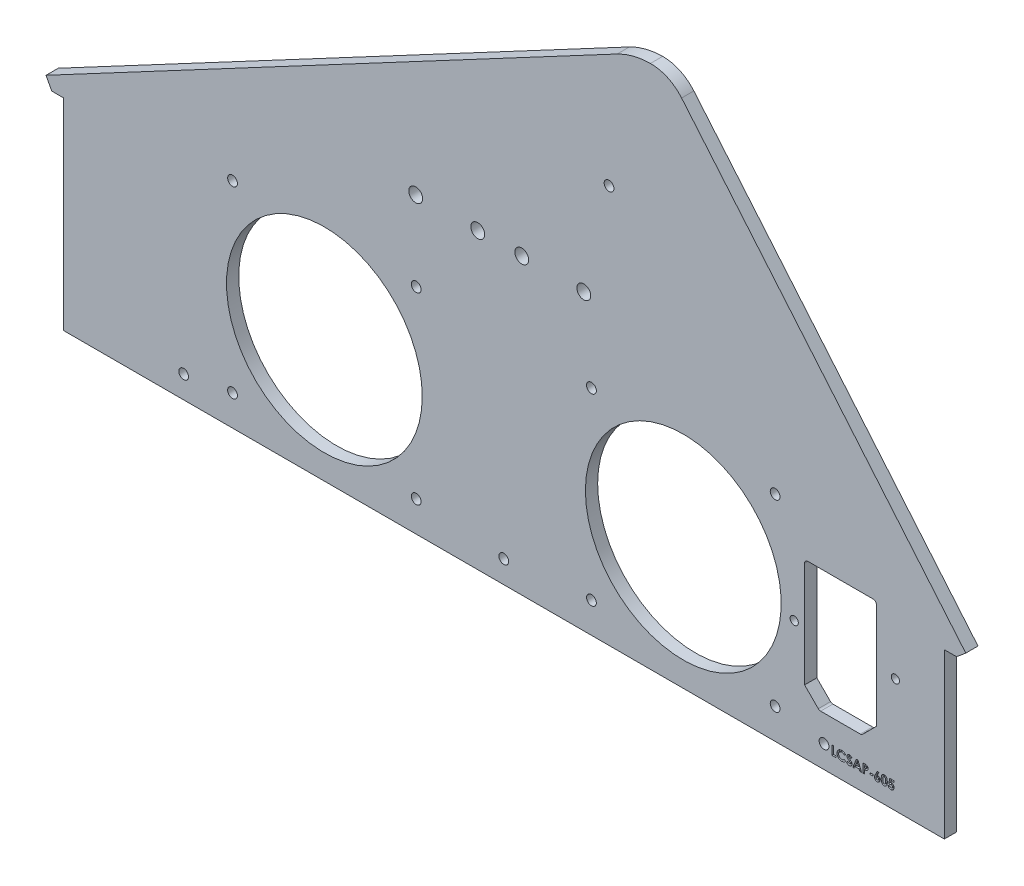
from build123d import *

# Parameters (mm, degrees)
BOSS_EXTRUDE1_DEPTH = 4.7625
SKETCH2_R           = 1.905
CUT_EXTRUDE1_DEPTH  = 407.344943003
SKETCH3_R           = 38.1
SKETCH3_R_2         = 1.905
CUT_EXTRUDE2_DEPTH  = 407.344943003
SKETCH4_R           = 2.69875
CUT_EXTRUDE3_DEPTH  = 407.344943003
SKETCH6_R           = 1.5875
CUT_EXTRUDE4_DEPTH  = 407.344943003
SKETCH7_W           = 1.211538462
SKETCH7_H           = 0.583333334
CUT_EXTRUDE5_DEPTH  = 1.016


with BuildPart() as part:
    # Sketch1 → Boss-Extrude1 (new body)
    with BuildSketch(Plane.XY):
        with BuildLine():
            Line((342.9, 0), (342.9, 63.846084025))
            Line((342.9, 63.846084025), (347.6625, 63.846084025))
            Line((347.6625, 63.846084025), (351.246350093, 66.853291317))
            Line((351.246350093, 66.853291317), (240.642270942, 198.6661))
            ThreePointArc((240.642270942, 198.6661), (235.199196057, 202.821062746), (228.502863126, 204.252811641))
            ThreePointArc((228.502863126, 204.252811641), (221.829642318, 203.38166914), (215.553659607, 200.9521))
            Line((215.553659607, 200.9521), (-6.746192899, 82.628723888))
            Line((-6.746192899, 82.628723888), (-4.5085, 78.424661955))
            Line((-4.5085, 78.424661955), (0, 78.424661955))
            Line((0, 78.424661955), (0, 0))
            Line((0, 0), (342.9, 0))
        make_face()
    extrude(amount=BOSS_EXTRUDE1_DEPTH)

    # Sketch2 → Cut-Extrude1 (cut, through all)
    with BuildSketch(Plane.XY):
        with Locations((46.8249, 8.73125)):
            Circle(SKETCH2_R)
        with Locations((296.0751, 8.73125)):
            Circle(SKETCH2_R)
        with Locations((171.4246, 8.73125)):
            Circle(SKETCH2_R)
        with Locations((212.41385, 154.94)):
            Circle(SKETCH2_R)
    extrude(amount=CUT_EXTRUDE1_DEPTH, mode=Mode.SUBTRACT)

    # Sketch3 → Cut-Extrude2 (cut, through all)
    with BuildSketch(Plane.XY):
        with Locations((101.6, 47.625)):
            Circle(SKETCH3_R)
        with Locations((137.35, 83.375)):
            Circle(SKETCH3_R_2)
        with Locations((65.85, 83.375)):
            Circle(SKETCH3_R_2)
        with Locations((65.85, 11.875)):
            Circle(SKETCH3_R_2)
        with Locations((137.35, 11.875)):
            Circle(SKETCH3_R_2)
        with Locations((205.55, 11.875)):
            Circle(SKETCH3_R_2)
        with Locations((277.05, 11.875)):
            Circle(SKETCH3_R_2)
        with Locations((277.05, 83.375)):
            Circle(SKETCH3_R_2)
        with Locations((205.55, 83.375)):
            Circle(SKETCH3_R_2)
        with Locations((241.3, 47.625)):
            Circle(SKETCH3_R)
    extrude(amount=CUT_EXTRUDE2_DEPTH, mode=Mode.SUBTRACT)

    # Sketch4 → Cut-Extrude3 (cut, through all)
    with BuildSketch(Plane.XY):
        with Locations((137.16, 114.3)):
            Circle(SKETCH4_R)
        with Locations((161.29, 114.3)):
            Circle(SKETCH4_R)
        with Locations((178.435, 114.3)):
            Circle(SKETCH4_R)
        with Locations((202.565, 114.3)):
            Circle(SKETCH4_R)
    extrude(amount=CUT_EXTRUDE3_DEPTH, mode=Mode.SUBTRACT)

    # Sketch6 → Cut-Extrude4 (cut, through all)
    with BuildSketch(Plane.XY):
        with Locations((284.48, 44.45)):
            Circle(SKETCH6_R)
        with Locations((323.85, 44.45)):
            Circle(SKETCH6_R)
        with BuildLine():
            Line((316.45, 24.765), (316.45, 65.786))
            ThreePointArc((316.45, 65.786), (316.078025612, 66.684025612), (315.18, 67.056))
            Line((315.18, 67.056), (289.78, 67.056))
            ThreePointArc((289.78, 67.056), (288.881974388, 66.684025612), (288.51, 65.786))
            Line((288.51, 65.786), (288.51, 24.765))
            Line((288.51, 24.765), (293.853025612, 19.421974388))
            ThreePointArc((293.853025612, 19.421974388), (294.265043265, 19.146672994), (294.751051224, 19.05))
            Line((294.751051224, 19.05), (310.208948776, 19.05))
            ThreePointArc((310.208948776, 19.05), (310.694956735, 19.146672994), (311.106974388, 19.421974388))
            Line((311.106974388, 19.421974388), (316.45, 24.765))
        make_face()
    extrude(amount=CUT_EXTRUDE4_DEPTH, mode=Mode.SUBTRACT)

    # Sketch7 → Cut-Extrude5 (cut)
    # profile 1 of 9: a face of its own
    with BuildSketch(Plane.XY.offset(4.7625)):
        with BuildLine():
            Line((321.671734776, 9.85), (323.265384615, 9.85))
            Line((323.265384615, 9.85), (323.265384615, 9.266666667))
            Line((323.265384615, 9.266666667), (322.16953125, 9.266666667))
            Line((322.16953125, 9.266666667), (322.0328125, 8.604807692))
            add(Edge.make_bspline(
                [(322.0328125, 8.604807692), (322.051442387, 8.609996351), (322.088184351, 8.620229452), (322.143536166, 8.630491957), (322.197179789, 8.637143787), (322.232380406, 8.638031053), (322.249459135, 8.638461538)],
                knots=[0, 0, 0, 0, 1.05461699, 2.079921384, 3.068411212, 4, 4, 4, 4], degree=3))
            add(Edge.make_bspline(
                [(322.249459135, 8.638461538), (322.286675472, 8.637608748), (322.360037073, 8.635927709), (322.467355785, 8.61996917), (322.570119791, 8.594834954), (322.668014623, 8.558988378), (322.76094465, 8.512333132), (322.849022522, 8.455893363), (322.932356339, 8.389569942), (323.009465742, 8.313321345), (323.080317083, 8.229598659), (323.141918283, 8.139043716), (323.194529551, 8.04294774), (323.236374736, 7.940713401), (323.269402522, 7.8329828), (323.293269139, 7.7196869), (323.307382661, 7.600691427), (323.309285783, 7.519509324), (323.31025641, 7.478104968)],
                knots=[0, 0, 0, 0, 1.01440847, 1.999622559, 2.951875003, 3.895578053, 4.836219714, 5.782137149, 6.743708247, 7.735272588, 8.734977101, 9.730283169, 10.717124674, 11.717316708, 12.737475749, 13.78628267, 14.87096371, 16, 16, 16, 16], degree=3))
            add(Edge.make_bspline(
                [(323.31025641, 7.478104968), (323.309070288, 7.436230577), (323.306729723, 7.353600162), (323.291459682, 7.232104224), (323.264507784, 7.115738544), (323.227486655, 7.004191613), (323.178713688, 6.898283274), (323.120057519, 6.796916397), (323.050526432, 6.700843395), (322.970802765, 6.611049133), (322.884132681, 6.528975454), (322.7918495, 6.456775081), (322.69460154, 6.396019052), (322.592386455, 6.346917909), (322.485790684, 6.308069959), (322.374781875, 6.279790505), (322.25882054, 6.26357381), (322.18009786, 6.261374362), (322.140084135, 6.26025641)],
                knots=[0, 0, 0, 0, 1.06808661, 2.107647099, 3.116961351, 4.110378221, 5.100014249, 6.085620622, 7.093190682, 8.119403071, 9.144090782, 10.133780668, 11.103064255, 12.062861538, 13.020824475, 13.992378307, 14.979551724, 16, 16, 16, 16], degree=3))
            add(Edge.make_bspline(
                [(322.140084135, 6.26025641), (322.104301051, 6.261170964), (322.033729322, 6.262974655), (321.929780263, 6.274061093), (321.829561827, 6.293662018), (321.733606064, 6.322029632), (321.64090336, 6.356943689), (321.552525383, 6.400610316), (321.467986482, 6.45219804), (321.387526715, 6.510765386), (321.31245344, 6.576739229), (321.243934509, 6.648958967), (321.1815551, 6.726514305), (321.126650035, 6.810362042), (321.079391424, 6.900378295), (321.037481525, 6.995502204), (321.003177852, 7.096727166), (320.985769726, 7.166901933), (320.976923077, 7.202564103)],
                knots=[0, 0, 0, 0, 1.054957082, 2.080596141, 3.077793124, 4.061112343, 5.027190972, 5.994718051, 6.962465889, 7.943658696, 8.924948258, 9.904494768, 10.875059, 11.855380583, 12.854004648, 13.869083016, 14.917087635, 16, 16, 16, 16], degree=3))
            Line((320.976923077, 7.202564103), (321.694871795, 7.202564103))
            add(Edge.make_bspline(
                [(321.694871795, 7.202564103), (321.707995915, 7.177851671), (321.733501144, 7.129825881), (321.782017729, 7.066064428), (321.836328965, 7.011691401), (321.895944937, 6.966175562), (321.961251917, 6.93207587), (322.029588771, 6.906216242), (322.101813985, 6.89127292), (322.151002544, 6.889404857), (322.175841346, 6.888461538)],
                knots=[0, 0, 0, 0, 1.104910296, 2.147267069, 3.153527244, 4.136738762, 5.099945312, 6.05603338, 7.018353, 8, 8, 8, 8], degree=3))
            add(Edge.make_bspline(
                [(322.175841346, 6.888461538), (322.193153658, 6.889112908), (322.227215923, 6.890394488), (322.277401284, 6.897174369), (322.325305416, 6.910015309), (322.371284475, 6.927797026), (322.415461972, 6.949972835), (322.457204607, 6.97796835), (322.497238628, 7.010192225), (322.534954553, 7.047169231), (322.56911431, 7.088389992), (322.59906868, 7.132684509), (322.625852018, 7.179068549), (322.645690846, 7.229379501), (322.661937169, 7.282115061), (322.673901618, 7.33767303), (322.681051725, 7.396118294), (322.681713634, 7.436017238), (322.682051282, 7.456370192)],
                knots=[0, 0, 0, 0, 0.978869489, 1.925942215, 2.855067702, 3.774946051, 4.70828698, 5.642468714, 6.60995405, 7.609372294, 8.622401667, 9.629904756, 10.629323, 11.642352373, 12.678539694, 13.745912462, 14.850161547, 16, 16, 16, 16], degree=3))
            add(Edge.make_bspline(
                [(322.682051282, 7.456370192), (322.681659403, 7.476250708), (322.6808966, 7.514948615), (322.674586541, 7.571771003), (322.663297967, 7.625685166), (322.647917189, 7.677104046), (322.628227956, 7.725715402), (322.604166398, 7.771808594), (322.57562972, 7.815150636), (322.542464716, 7.854859127), (322.507097896, 7.891280884), (322.469102568, 7.923135063), (322.428821049, 7.94957182), (322.387505036, 7.972651878), (322.343505345, 7.989449041), (322.297811351, 8.001016627), (322.250471107, 8.009504457), (322.218181354, 8.010003148), (322.201782853, 8.01025641)],
                knots=[0, 0, 0, 0, 1.166249705, 2.270133367, 3.348514167, 4.393962215, 5.415026464, 6.420877785, 7.440098956, 8.453121383, 9.451844239, 10.415694839, 11.355045125, 12.27538808, 13.187007209, 14.108269027, 15.039275622, 16, 16, 16, 16], degree=3))
            add(Edge.make_bspline(
                [(322.201782853, 8.01025641), (322.183970269, 8.009580522), (322.14827003, 8.008225896), (322.09522841, 7.997203668), (322.042826324, 7.979365569), (321.990772364, 7.954755084), (321.939583254, 7.922547724), (321.887908089, 7.884772184), (321.837476548, 7.838683712), (321.805410771, 7.804356913), (321.788822115, 7.786598558)],
                knots=[0, 0, 0, 0, 0.88288272, 1.769486374, 2.674910571, 3.623812639, 4.617874466, 5.670434592, 6.794841017, 8, 8, 8, 8], degree=3))
            Line((321.788822115, 7.786598558), (321.260176282, 7.907892628))
            Line((321.260176282, 7.907892628), (321.671734776, 9.85))
        make_face()
    # profile 2 of 9: a face of its own
    with BuildSketch(Plane.XY.offset(4.7625)):
        with BuildLine():
            add(Edge.make_bspline(
                [(319.508072917, 9.93974359), (319.538480652, 9.939292178), (319.598270385, 9.938404583), (319.686329406, 9.928791201), (319.771154591, 9.914268063), (319.853077785, 9.894013349), (319.931509297, 9.867206957), (320.007019968, 9.835120165), (320.078711003, 9.796069956), (320.147496691, 9.751960738), (320.213350535, 9.702022851), (320.274689786, 9.64509108), (320.332634627, 9.58247543), (320.385930767, 9.513229263), (320.435758465, 9.437982447), (320.481953994, 9.35672305), (320.524163718, 9.269053361), (320.562860706, 9.174815174), (320.597463675, 9.072595899), (320.626609713, 8.961223037), (320.651607317, 8.840671153), (320.672707059, 8.710640176), (320.688655053, 8.570957264), (320.699404323, 8.421715214), (320.70678098, 8.263201744), (320.707383012, 8.154462806), (320.707692308, 8.098597756)],
                knots=[0, 0, 0, 0, 0.879237366, 1.728815576, 2.559023295, 3.367336655, 4.166867292, 4.954216142, 5.737608147, 6.525189134, 7.316157332, 8.124696809, 8.942788509, 9.781158001, 10.649253743, 11.551476218, 12.482711956, 13.461909668, 14.496590415, 15.601789533, 16.789733467, 18.056700938, 19.410929216, 20.8549011, 22.384193279, 24, 24, 24, 24], degree=3))
            add(Edge.make_bspline(
                [(320.707692308, 8.098597756), (320.707358042, 8.042033772), (320.706708571, 7.932130965), (320.699710973, 7.77216765), (320.687660778, 7.621842014), (320.672129618, 7.481169608), (320.650856176, 7.350224719), (320.625942019, 7.228668289), (320.59633592, 7.116544378), (320.560593141, 7.014105625), (320.522130387, 6.919701935), (320.479805201, 6.832203181), (320.434355307, 6.751372369), (320.386823186, 6.675990055), (320.334602955, 6.608278471), (320.280236318, 6.545935071), (320.221356056, 6.491334593), (320.160441254, 6.441663175), (320.095260358, 6.398737102), (320.02648556, 6.361194666), (319.952890726, 6.330743291), (319.875817364, 6.304258312), (319.793951743, 6.285244955), (319.708594697, 6.27015848), (319.618782561, 6.261820769), (319.557634842, 6.260786421), (319.526302083, 6.26025641)],
                knots=[0, 0, 0, 0, 1.643780988, 3.193836972, 4.651895693, 6.025988579, 7.305620092, 8.505800249, 9.631074763, 10.672816429, 11.65661981, 12.592235626, 13.49536222, 14.350718032, 15.179365177, 15.97804903, 16.751647189, 17.51006938, 18.259804725, 19.016521909, 19.783502495, 20.571750527, 21.382245291, 22.22305063, 23.089471752, 24, 24, 24, 24], degree=3))
            add(Edge.make_bspline(
                [(319.526302083, 6.26025641), (319.49497017, 6.260796645), (319.433591414, 6.261854957), (319.343536417, 6.270096486), (319.257727022, 6.28530607), (319.175213712, 6.304404282), (319.096570768, 6.33068469), (319.0214211, 6.362047148), (318.950342543, 6.399355338), (318.883138292, 6.442381425), (318.820037802, 6.491720504), (318.76006049, 6.546844838), (318.703339031, 6.607614701), (318.650736299, 6.674710765), (318.601390812, 6.747237439), (318.555817167, 6.826022941), (318.514042751, 6.910952561), (318.474760854, 7.002144684), (318.440629858, 7.10156257), (318.410254856, 7.210094009), (318.385372454, 7.3286437), (318.36536036, 7.457173557), (318.349382717, 7.595411285), (318.337497186, 7.743423606), (318.33046072, 7.901279462), (318.329818059, 8.009781655), (318.329487179, 8.065645032)],
                knots=[0, 0, 0, 0, 0.917216111, 1.796812873, 2.643793957, 3.46689424, 4.273913431, 5.068098542, 5.848489301, 6.620921603, 7.401012384, 8.190319798, 9.003608147, 9.831726257, 10.68377682, 11.569763213, 12.493818149, 13.453288342, 14.474581811, 15.568529029, 16.750744269, 18.018426408, 19.375425659, 20.823733699, 22.36466933, 24, 24, 24, 24], degree=3))
            add(Edge.make_bspline(
                [(318.329487179, 8.065645032), (318.330086537, 8.143262797), (318.331243006, 8.293027275), (318.345898626, 8.509393402), (318.36740936, 8.709386406), (318.399003532, 8.892671749), (318.438069289, 9.059928265), (318.488095025, 9.210054156), (318.545045686, 9.345126752), (318.593574966, 9.425144571), (318.616947115, 9.463681891)],
                knots=[0, 0, 0, 0, 1.288568992, 2.486310467, 3.599230591, 4.627010532, 5.572937695, 6.447898582, 7.252493626, 8, 8, 8, 8], degree=3))
            add(Edge.make_bspline(
                [(318.616947115, 9.463681891), (318.644123137, 9.501540942), (318.697257615, 9.575562848), (318.790164735, 9.672739774), (318.889981339, 9.755850239), (318.998757603, 9.82301338), (319.114773185, 9.875978238), (319.239024139, 9.913386721), (319.371051626, 9.935182647), (319.461717103, 9.938200572), (319.508072917, 9.93974359)],
                knots=[0, 0, 0, 0, 1.058512271, 2.069600068, 3.047294572, 4.004278952, 4.967380941, 5.939006123, 6.946246673, 8, 8, 8, 8], degree=3))
        make_face()
        with BuildLine():
            add(Edge.make_bspline(
                [(319.523497596, 9.311538462), (319.496008751, 9.310235545), (319.442116023, 9.307681137), (319.363915106, 9.285997815), (319.290176524, 9.252506756), (319.234085555, 9.212205503), (319.192102022, 9.173571918), (319.162767826, 9.138609781), (319.134479618, 9.099594555), (319.109494048, 9.054765685), (319.085901148, 9.005733924), (319.062843773, 8.952276698), (319.04394278, 8.893080981), (319.025373055, 8.829154885), (319.009104244, 8.758731022), (318.995474546, 8.681233756), (318.98329761, 8.596159114), (318.974804052, 8.503451372), (318.966885506, 8.403207526), (318.961209118, 8.295204271), (318.958835962, 8.179470744), (318.958081608, 8.099766781), (318.957692308, 8.058633814)],
                knots=[0, 0, 0, 0, 1.076674018, 2.110852608, 3.161083442, 4.239746716, 4.804137807, 5.395870207, 6.026861976, 6.692161227, 7.405688833, 8.16177676, 8.973626916, 9.841385931, 10.773283133, 11.807421078, 12.927755683, 14.143907515, 15.458935494, 16.872852025, 18.386167141, 20, 20, 20, 20], degree=3))
            add(Edge.make_bspline(
                [(318.957692308, 8.058633814), (318.95833305, 8.005344067), (318.95956172, 7.903157026), (318.965996919, 7.756208503), (318.978895741, 7.622473515), (318.994939272, 7.501045689), (319.017473067, 7.392712518), (319.043399656, 7.29644907), (319.075416688, 7.21348247), (319.112418538, 7.142612834), (319.153399754, 7.082324181), (319.197886667, 7.031078555), (319.244364656, 6.986702261), (319.294284452, 6.950655944), (319.34752696, 6.923031708), (319.403647703, 6.903161936), (319.462682345, 6.890998822), (319.503108659, 6.889312189), (319.523497596, 6.888461538)],
                knots=[0, 0, 0, 0, 1.771748488, 3.397459088, 4.888034009, 6.237357457, 7.467047327, 8.564189669, 9.548206622, 10.417051504, 11.216568818, 11.965764335, 12.669334354, 13.348544111, 14.005342236, 14.656555988, 15.322436492, 16, 16, 16, 16], degree=3))
            add(Edge.make_bspline(
                [(319.523497596, 6.888461538), (319.54318685, 6.889043617), (319.581735959, 6.890183253), (319.637949195, 6.901881469), (319.691108425, 6.920900227), (319.741053145, 6.947803595), (319.787962, 6.982015344), (319.831605729, 7.023685815), (319.871655179, 7.073230366), (319.894988171, 7.109999749), (319.907011218, 7.128946314)],
                knots=[0, 0, 0, 0, 0.992283464, 1.942767638, 2.88273346, 3.832339453, 4.79467288, 5.803907806, 6.868395428, 8, 8, 8, 8], degree=3))
            add(Edge.make_bspline(
                [(319.907011218, 7.128946314), (319.921166331, 7.154836189), (319.950848455, 7.209125158), (319.985196661, 7.300735767), (320.014109066, 7.404057394), (320.03899355, 7.519411585), (320.056013019, 7.64725331), (320.070670165, 7.786771915), (320.077739671, 7.938669958), (320.078889565, 8.04390547), (320.079487179, 8.098597756)],
                knots=[0, 0, 0, 0, 0.710965849, 1.490837728, 2.352621235, 3.297892224, 4.334225155, 5.461620853, 6.680770821, 8, 8, 8, 8], degree=3))
            add(Edge.make_bspline(
                [(320.079487179, 8.098597756), (320.079256334, 8.153764798), (320.078811995, 8.259951935), (320.070659668, 8.412396063), (320.05930693, 8.551628473), (320.042701151, 8.677338316), (320.021334799, 8.789830761), (319.995000689, 8.889098454), (319.963954732, 8.975337033), (319.927137927, 9.048460505), (319.886361029, 9.110605426), (319.843075106, 9.163920947), (319.797097128, 9.209440394), (319.748503986, 9.247335064), (319.696170975, 9.276289435), (319.641097722, 9.296733616), (319.583171324, 9.309101659), (319.54365732, 9.310715231), (319.523497596, 9.311538462)],
                knots=[0, 0, 0, 0, 1.793836731, 3.452829483, 4.963243077, 6.335886805, 7.574563692, 8.684454726, 9.672768357, 10.54971625, 11.340229787, 12.085688095, 12.778991901, 13.440269426, 14.083255152, 14.715733572, 15.344777694, 16, 16, 16, 16], degree=3))
        make_face(mode=Mode.SUBTRACT)
    # profile 3 of 9: a face of its own
    with BuildSketch(Plane.XY.offset(4.7625)):
        with BuildLine():
            Line((316.879567308, 9.93974359), (317.435556891, 9.657892628))
            Line((317.435556891, 9.657892628), (316.825580929, 8.458974359))
            add(Edge.make_bspline(
                [(316.825580929, 8.458974359), (316.861617737, 8.458041348), (316.932598139, 8.456203629), (317.037031398, 8.441350882), (317.136871538, 8.415674043), (317.233125242, 8.381639463), (317.3246159, 8.335930683), (317.41281702, 8.281557705), (317.495446794, 8.21524401), (317.574399853, 8.141771954), (317.646191464, 8.060375475), (317.70855517, 7.972912373), (317.762904039, 7.881510636), (317.805152663, 7.784125384), (317.839231809, 7.68237089), (317.863821413, 7.575840396), (317.87785047, 7.464225415), (317.87978461, 7.388400302), (317.880769231, 7.349799679)],
                knots=[0, 0, 0, 0, 1.013260694, 1.995783107, 2.958651975, 3.908806537, 4.861209129, 5.829647963, 6.817170299, 7.835534541, 8.860094905, 9.863329007, 10.853101798, 11.844815043, 12.84250023, 13.867713965, 14.914507806, 16, 16, 16, 16], degree=3))
            add(Edge.make_bspline(
                [(317.880769231, 7.349799679), (317.87984656, 7.312591021), (317.878022834, 7.239045459), (317.862947329, 7.131025732), (317.838584522, 7.027387122), (317.803765177, 6.928336607), (317.759506974, 6.833390025), (317.70538219, 6.742603092), (317.640941964, 6.656654229), (317.567851255, 6.576000127), (317.4879505, 6.502483317), (317.403730752, 6.437137297), (317.314478345, 6.383159006), (317.221880252, 6.337573073), (317.124231686, 6.303556092), (317.022993963, 6.277879165), (316.917399368, 6.263062463), (316.845724462, 6.261199246), (316.809455128, 6.26025641)],
                knots=[0, 0, 0, 0, 1.049934834, 2.075270938, 3.072134561, 4.05064612, 5.033440221, 6.024524368, 7.028587226, 8.060776465, 9.092543989, 10.090062252, 11.064205434, 12.031961459, 12.998029633, 13.977230324, 14.976426867, 16, 16, 16, 16], degree=3))
            add(Edge.make_bspline(
                [(316.809455128, 6.26025641), (316.771528427, 6.261030145), (316.696950701, 6.26255159), (316.587824824, 6.279587767), (316.483163715, 6.305233356), (316.383555588, 6.3418509), (316.288381009, 6.388476396), (316.198760487, 6.446170758), (316.113939094, 6.514297771), (316.034821149, 6.591324685), (315.963541777, 6.675697131), (315.899966534, 6.763297697), (315.846181797, 6.854263848), (315.802644306, 6.948498322), (315.768675345, 7.045700839), (315.745039877, 7.14605588), (315.729639188, 7.249297254), (315.727833809, 7.319362693), (315.726923077, 7.354707532)],
                knots=[0, 0, 0, 0, 1.063775006, 2.091769615, 3.092589432, 4.084662827, 5.064601646, 6.061867366, 7.070035304, 8.113879863, 9.156342271, 10.166834137, 11.149076039, 12.117706134, 13.076241869, 14.034148791, 15.008317125, 16, 16, 16, 16], degree=3))
            add(Edge.make_bspline(
                [(315.726923077, 7.354707532), (315.72740429, 7.382077976), (315.728369394, 7.436971218), (315.738068118, 7.519170865), (315.752813586, 7.601586278), (315.769905513, 7.671131014), (315.787505052, 7.729938366), (315.805219124, 7.779705439), (315.827171813, 7.834936007), (315.852266989, 7.895771109), (315.881293802, 7.962137558), (315.914100623, 8.033854458), (315.950769126, 8.111464902), (315.976918819, 8.16477126), (315.990544872, 8.192548077)],
                knots=[0, 0, 0, 0, 1.110454016, 2.227089276, 3.35462975, 4.507227546, 5.131400587, 5.845402449, 6.650387134, 7.543487832, 8.516250726, 9.590168902, 10.744287919, 12, 12, 12, 12], degree=3))
            Line((315.990544872, 8.192548077), (316.879567308, 9.93974359))
        make_face()
        with BuildLine():
            add(Edge.make_bspline(
                [(316.795432692, 7.875641026), (316.765289498, 7.874258421), (316.706303224, 7.871552845), (316.622433564, 7.843218739), (316.545963463, 7.798769578), (316.479678234, 7.736865525), (316.424236738, 7.662887751), (316.383496382, 7.578506218), (316.358988794, 7.484846975), (316.356442612, 7.419361994), (316.355128205, 7.385556891)],
                knots=[0, 0, 0, 0, 0.981744412, 1.921144944, 2.858899012, 3.85339082, 4.86292663, 5.863643845, 6.897155691, 8, 8, 8, 8], degree=3))
            add(Edge.make_bspline(
                [(316.355128205, 7.385556891), (316.356684504, 7.351740531), (316.35971161, 7.285965451), (316.385140716, 7.191414405), (316.426776052, 7.105116665), (316.485166957, 7.030158525), (316.553717039, 6.967937465), (316.62973095, 6.921922016), (316.71194075, 6.893653216), (316.768807276, 6.890204047), (316.797536058, 6.888461538)],
                knots=[0, 0, 0, 0, 1.098279937, 2.136227893, 3.159405121, 4.194678092, 5.206500211, 6.154139736, 7.067477469, 8, 8, 8, 8], degree=3))
            add(Edge.make_bspline(
                [(316.797536058, 6.888461538), (316.827876898, 6.890235082), (316.887380557, 6.89371331), (316.973218487, 6.920792611), (317.051631951, 6.96603715), (317.12096462, 7.028059004), (317.180520066, 7.102161771), (317.221726419, 7.188966412), (317.248331124, 7.284199894), (317.251121474, 7.351013724), (317.252564103, 7.385556891)],
                knots=[0, 0, 0, 0, 0.96921794, 1.900804717, 2.848419905, 3.844199796, 4.861108892, 5.867439427, 6.897452859, 8, 8, 8, 8], degree=3))
            add(Edge.make_bspline(
                [(317.252564103, 7.385556891), (317.250920685, 7.419342255), (317.247738015, 7.484771558), (317.223832395, 7.578869573), (317.181150523, 7.662925868), (317.124454619, 7.737170894), (317.055888204, 7.799047343), (316.976357614, 7.843569279), (316.888656648, 7.871502646), (316.826960415, 7.874241453), (316.795432692, 7.875641026)],
                knots=[0, 0, 0, 0, 1.083229974, 2.097801324, 3.086792542, 4.086858909, 5.079819718, 6.026392613, 6.991456328, 8, 8, 8, 8], degree=3))
        make_face(mode=Mode.SUBTRACT)
    # profile 4 of 9: a face of its own
    with BuildSketch(Plane.XY.offset(4.7625)):
        with Locations((314.492948718, 7.628846154)):
            Rectangle(SKETCH7_W, SKETCH7_H)
    # profile 5 of 9: a face of its own
    with BuildSketch(Plane.XY.offset(4.7625)):
        with BuildLine():
            Line((311.194871795, 9.85), (311.89599359, 9.85))
            add(Edge.make_bspline(
                [(311.89599359, 9.85), (311.941803978, 9.849794943), (312.03018182, 9.849399345), (312.157629939, 9.844602193), (312.27520707, 9.836005403), (312.382886197, 9.825381131), (312.480623048, 9.810486316), (312.568540018, 9.793410575), (312.646655351, 9.772607354), (312.715849914, 9.747914219), (312.777949799, 9.718801977), (312.83671632, 9.687795361), (312.890821346, 9.650790059), (312.942995721, 9.611774345), (312.990256547, 9.567021062), (313.035552237, 9.519508606), (313.076964394, 9.467352673), (313.114684908, 9.411184597), (313.148903226, 9.352042122), (313.178798638, 9.28981952), (313.203048122, 9.22441833), (313.223390424, 9.156261623), (313.239729559, 9.085352371), (313.250605407, 9.011254473), (313.25799283, 8.934485311), (313.258644668, 8.882236171), (313.258974359, 8.855809295)],
                knots=[0, 0, 0, 0, 1.698747864, 3.27724071, 4.728299578, 6.070144658, 7.288476769, 8.393259625, 9.389771311, 10.283485332, 11.113357557, 11.931608583, 12.74405601, 13.541433047, 14.344816069, 15.154114104, 15.974336324, 16.810834471, 17.661136416, 18.50621059, 19.367396281, 20.244825668, 21.142564693, 22.063065223, 23.020325768, 24, 24, 24, 24], degree=3))
            add(Edge.make_bspline(
                [(313.258974359, 8.855809295), (313.258497338, 8.826573871), (313.257559933, 8.769122669), (313.248370347, 8.684906257), (313.23267163, 8.604613532), (313.212154229, 8.527567372), (313.183544171, 8.455035358), (313.150858523, 8.385286853), (313.11064481, 8.320277391), (313.064694213, 8.259193782), (313.014510919, 8.201539387), (312.958903578, 8.148978868), (312.898932091, 8.101153923), (312.834943611, 8.057563341), (312.766697906, 8.018295054), (312.694244218, 7.982981357), (312.617087793, 7.952751692), (312.56335838, 7.936941821), (312.536117788, 7.928926282)],
                knots=[0, 0, 0, 0, 1.102006807, 2.165578795, 3.188629044, 4.184801286, 5.166646146, 6.124351954, 7.085497154, 8.042432466, 9.003981491, 9.963833307, 10.922997304, 11.89326795, 12.880200226, 13.889073926, 14.929769137, 16, 16, 16, 16], degree=3))
            add(Edge.make_bspline(
                [(312.536117788, 7.928926282), (312.518175568, 7.924462228), (312.479306939, 7.914791651), (312.414990035, 7.904973587), (312.340871557, 7.895946482), (312.25671183, 7.888188777), (312.162462334, 7.882915346), (312.058214328, 7.87879703), (311.943920568, 7.87580259), (311.864445207, 7.875696334), (311.823076923, 7.875641026)],
                knots=[0, 0, 0, 0, 0.618981996, 1.340914327, 2.176866532, 3.120127938, 4.170906482, 5.338178032, 6.614476169, 8, 8, 8, 8], degree=3))
            Line((311.823076923, 7.875641026), (311.823076923, 6.35))
            Line((311.823076923, 6.35), (311.194871795, 6.35))
            Line((311.194871795, 6.35), (311.194871795, 9.85))
        make_face()
        with BuildLine():
            Line((311.823076923, 8.503846154), (312.045332532, 8.503846154))
            add(Edge.make_bspline(
                [(312.045332532, 8.503846154), (312.085775449, 8.504102593), (312.160191017, 8.504574446), (312.261816404, 8.511397707), (312.343484521, 8.521818204), (312.408003849, 8.536763608), (312.45894797, 8.559445236), (312.502884084, 8.585683609), (312.540569212, 8.618861312), (312.573198985, 8.656772514), (312.599285506, 8.700334385), (312.617375149, 8.748837605), (312.629125826, 8.801263069), (312.63021111, 8.837747722), (312.630769231, 8.856510417)],
                knots=[0, 0, 0, 0, 1.8619151, 3.425951444, 4.686033666, 5.651700536, 6.461346321, 7.243864085, 7.999046032, 8.762387399, 9.539336099, 10.322741239, 11.137448474, 12, 12, 12, 12], degree=3))
            add(Edge.make_bspline(
                [(312.630769231, 8.856510417), (312.630216851, 8.872903138), (312.629145101, 8.904708959), (312.621271733, 8.950612649), (312.608723849, 8.993404356), (312.590542447, 9.03263718), (312.567038201, 9.068244457), (312.538381767, 9.100212159), (312.504940866, 9.129224904), (312.479122535, 9.144581793), (312.466005609, 9.152383814)],
                knots=[0, 0, 0, 0, 1.102301479, 2.1387299, 3.123554645, 4.094223062, 5.036071848, 5.982632524, 6.975082478, 8, 8, 8, 8], degree=3))
            add(Edge.make_bspline(
                [(312.466005609, 9.152383814), (312.454894815, 9.158002861), (312.431370989, 9.169899535), (312.391307631, 9.183730288), (312.345075129, 9.195398051), (312.292361359, 9.205082183), (312.233376613, 9.212598074), (312.168131415, 9.218345851), (312.096529749, 9.220657256), (312.046735075, 9.221405207), (312.020793269, 9.221794872)],
                knots=[0, 0, 0, 0, 0.656809284, 1.390599849, 2.23162475, 3.173112763, 4.218524733, 5.370385145, 6.63003504, 8, 8, 8, 8], degree=3))
            Line((312.020793269, 9.221794872), (311.823076923, 9.221794872))
            Line((311.823076923, 9.221794872), (311.823076923, 8.503846154))
        make_face(mode=Mode.SUBTRACT)
    # profile 6 of 9: a face of its own
    with BuildSketch(Plane.XY.offset(4.7625)):
        Polygon((308.682752404, 9.85), (309.265384615, 9.85), (310.678846154, 6.35), (310.007872596, 6.35), (309.73583734, 7.067948718), (308.210897436, 7.067948718), (307.938862179, 6.35), (307.268589744, 6.35), align=None)
        Polygon((308.973717949, 8.911197917), (308.449278846, 7.696153846), (309.498157051, 7.696153846), align=None, mode=Mode.SUBTRACT)
    # profile 7 of 9: a face of its own
    with BuildSketch(Plane.XY.offset(4.7625)):
        with BuildLine():
            Line((306.887179487, 9.382351763), (306.417427885, 8.952564103))
            add(Edge.make_bspline(
                [(306.417427885, 8.952564103), (306.39730574, 8.980948479), (306.358674029, 9.035442524), (306.296056055, 9.108411334), (306.233720833, 9.17065916), (306.171090865, 9.221925958), (306.107611023, 9.261900244), (306.0433915, 9.290202481), (305.978796372, 9.308194481), (305.935398418, 9.310434918), (305.914022436, 9.311538462)],
                knots=[0, 0, 0, 0, 1.299362458, 2.494594718, 3.587462134, 4.587049575, 5.512617175, 6.380583204, 7.202344345, 8, 8, 8, 8], degree=3))
            add(Edge.make_bspline(
                [(305.914022436, 9.311538462), (305.894083533, 9.310839206), (305.855586751, 9.309489126), (305.800706732, 9.296069437), (305.751983469, 9.272909025), (305.709464515, 9.242624837), (305.67578323, 9.206139412), (305.648891336, 9.167875583), (305.63374894, 9.125640968), (305.631755902, 9.096632532), (305.630769231, 9.082271635)],
                knots=[0, 0, 0, 0, 1.185010067, 2.2879431, 3.333075148, 4.379039566, 5.372662701, 6.27520591, 7.14612461, 8, 8, 8, 8], degree=3))
            add(Edge.make_bspline(
                [(305.630769231, 9.082271635), (305.631387528, 9.067703647), (305.632632692, 9.038365745), (305.644659286, 8.995367395), (305.662786797, 8.953353002), (305.680108374, 8.927776842), (305.68896234, 8.914703526)],
                knots=[0, 0, 0, 0, 0.967525499, 1.948461899, 2.951351359, 4, 4, 4, 4], degree=3))
            add(Edge.make_bspline(
                [(305.68896234, 8.914703526), (305.697011552, 8.904541774), (305.715539777, 8.881150764), (305.750869306, 8.84410305), (305.795235775, 8.798716357), (305.850346498, 8.746551401), (305.913913679, 8.685732126), (305.988883738, 8.618649361), (306.073098709, 8.543225631), (306.13295676, 8.490703276), (306.164322917, 8.46318109)],
                knots=[0, 0, 0, 0, 0.473873513, 1.090794244, 1.870441696, 2.795289791, 3.865433203, 5.087734844, 6.473946851, 8, 8, 8, 8], degree=3))
            add(Edge.make_bspline(
                [(306.164322917, 8.46318109), (306.193764567, 8.437700826), (306.249638703, 8.38934458), (306.329136503, 8.320710653), (306.399001829, 8.258962381), (306.460252459, 8.205026476), (306.511959893, 8.158337026), (306.554341511, 8.118670855), (306.587914931, 8.086800191), (306.606999454, 8.067550291), (306.615144231, 8.059334936)],
                knots=[0, 0, 0, 0, 1.543621617, 2.929473131, 4.163658386, 5.240097082, 6.164993805, 6.925417477, 7.541396219, 8, 8, 8, 8], degree=3))
            add(Edge.make_bspline(
                [(306.615144231, 8.059334936), (306.646043815, 8.025894968), (306.705443668, 7.961611605), (306.782642537, 7.861992611), (306.846179703, 7.764744159), (306.89533326, 7.668036363), (306.932456003, 7.570473922), (306.958628028, 7.469664122), (306.974302628, 7.364553564), (306.976042875, 7.292828439), (306.976923077, 7.256550481)],
                knots=[0, 0, 0, 0, 1.206664779, 2.319633467, 3.337109185, 4.282041471, 5.190008762, 6.099243693, 7.03861361, 8, 8, 8, 8], degree=3))
            add(Edge.make_bspline(
                [(306.976923077, 7.256550481), (306.976296572, 7.221202059), (306.975067345, 7.151847141), (306.960011678, 7.050356549), (306.938543179, 6.953225647), (306.905349114, 6.861511358), (306.864892385, 6.773708218), (306.814174031, 6.691183923), (306.754612279, 6.613103292), (306.686345367, 6.540862112), (306.610834055, 6.475308248), (306.529840996, 6.41695065), (306.4425742, 6.36876902), (306.34977926, 6.329094884), (306.251505848, 6.298537334), (306.147871036, 6.275952457), (306.038716308, 6.262397369), (305.964074733, 6.260980346), (305.925941506, 6.26025641)],
                knots=[0, 0, 0, 0, 1.043214005, 2.046824704, 3.02475056, 3.976699089, 4.921714032, 5.875962561, 6.831408892, 7.817874052, 8.806269674, 9.781291748, 10.760897367, 11.74438705, 12.757449933, 13.795994037, 14.874007457, 16, 16, 16, 16], degree=3))
            add(Edge.make_bspline(
                [(305.925941506, 6.26025641), (305.896007249, 6.260787464), (305.836720251, 6.261839255), (305.749340179, 6.270426251), (305.664964843, 6.284284751), (305.583689282, 6.30414812), (305.505147336, 6.329317702), (305.42933578, 6.360061383), (305.356777966, 6.396855678), (305.286924887, 6.43894395), (305.220116116, 6.487813977), (305.155506881, 6.542466629), (305.093738943, 6.603742487), (305.034515643, 6.671496636), (304.978215908, 6.74592094), (304.922996846, 6.825978902), (304.871312559, 6.91315629), (304.839384875, 6.974311933), (304.823076923, 7.005548878)],
                knots=[0, 0, 0, 0, 1.016823716, 2.013894106, 2.979844003, 3.91962641, 4.853723003, 5.779685073, 6.695824784, 7.614987388, 8.547259901, 9.504950863, 10.487499108, 11.500346958, 12.559593716, 13.656357062, 14.802919212, 16, 16, 16, 16], degree=3))
            Line((304.823076923, 7.005548878), (305.375560897, 7.337179487))
            add(Edge.make_bspline(
                [(305.375560897, 7.337179487), (305.395959708, 7.301721473), (305.435065971, 7.23374543), (305.501335191, 7.142411001), (305.569224623, 7.064198182), (305.64030381, 7.000489388), (305.713708457, 6.950432751), (305.789793124, 6.914658806), (305.868611268, 6.892514774), (305.922298607, 6.889810476), (305.949078526, 6.888461538)],
                knots=[0, 0, 0, 0, 1.283663364, 2.460892379, 3.537111102, 4.529833553, 5.449777664, 6.316464042, 7.160231139, 8, 8, 8, 8], degree=3))
            add(Edge.make_bspline(
                [(305.949078526, 6.888461538), (305.976317537, 6.889563154), (306.029165185, 6.891700449), (306.10459844, 6.911441996), (306.173758505, 6.942437673), (306.233539954, 6.98666423), (306.284159116, 7.037708399), (306.321518963, 7.094497371), (306.344988671, 7.155941668), (306.347469988, 7.198624918), (306.348717949, 7.220092147)],
                knots=[0, 0, 0, 0, 1.13588714, 2.203786484, 3.234766741, 4.283437687, 5.291419208, 6.222934724, 7.106237994, 8, 8, 8, 8], degree=3))
            add(Edge.make_bspline(
                [(306.348717949, 7.220092147), (306.347565508, 7.240063911), (306.345224436, 7.280634636), (306.32798082, 7.34095678), (306.301023789, 7.401251492), (306.269131721, 7.450706845), (306.236677547, 7.492114472), (306.205644037, 7.527992307), (306.167853432, 7.567631034), (306.123401551, 7.611080516), (306.07287572, 7.658723248), (306.016233377, 7.710554566), (305.952825908, 7.766117898), (305.908009383, 7.80396709), (305.884575321, 7.823758013)],
                knots=[0, 0, 0, 0, 0.916159276, 1.861089862, 2.860218735, 3.940849679, 4.552606315, 5.27541173, 6.11797699, 7.06649574, 8.129236253, 9.306560635, 10.591630461, 12, 12, 12, 12], degree=3))
            add(Edge.make_bspline(
                [(305.884575321, 7.823758013), (305.840026234, 7.861450812), (305.754523053, 7.933794702), (305.633696211, 8.04064435), (305.524820407, 8.140505137), (305.428836011, 8.23461156), (305.344520031, 8.321225691), (305.272443494, 8.401051045), (305.213398192, 8.474703364), (305.151265743, 8.561939606), (305.092227494, 8.668242962), (305.041201694, 8.796138223), (305.008098308, 8.924017255), (305.004389534, 9.009868194), (305.002564103, 9.052123397)],
                knots=[0, 0, 0, 0, 1.345494975, 2.582412109, 3.71882943, 4.751509156, 5.681369928, 6.505683931, 7.230279997, 7.856715994, 8.973648664, 10.023341002, 11.027102913, 12, 12, 12, 12], degree=3))
            add(Edge.make_bspline(
                [(305.002564103, 9.052123397), (305.003323297, 9.08208852), (305.004818992, 9.14112303), (305.018160819, 9.227924675), (305.038100688, 9.311680969), (305.067059103, 9.392086331), (305.104643629, 9.469040051), (305.150288575, 9.542918848), (305.204702722, 9.613042759), (305.266023792, 9.679365297), (305.333583912, 9.739976549), (305.405780485, 9.793472052), (305.482204873, 9.838655132), (305.56238955, 9.876137778), (305.646831387, 9.904828362), (305.734908306, 9.925165678), (305.826746635, 9.937261665), (305.889213085, 9.938905974), (305.921033654, 9.93974359)],
                knots=[0, 0, 0, 0, 1.010766082, 1.991317756, 2.957454644, 3.913069143, 4.869106762, 5.843196583, 6.838735724, 7.860187025, 8.887984031, 9.89767229, 10.887916223, 11.879572884, 12.879850636, 13.892031539, 14.926195476, 16, 16, 16, 16], degree=3))
            add(Edge.make_bspline(
                [(305.921033654, 9.93974359), (305.962271536, 9.93823502), (306.044421784, 9.935229789), (306.165883295, 9.911729864), (306.284521821, 9.874773756), (306.380122968, 9.830190278), (306.456191016, 9.787002242), (306.514490069, 9.747240139), (306.573812494, 9.701690512), (306.634636689, 9.650209824), (306.695832446, 9.59182811), (306.759139854, 9.527935192), (306.823696271, 9.457978887), (306.865647706, 9.408002427), (306.887179487, 9.382351763)],
                knots=[0, 0, 0, 0, 1.282922637, 2.555718331, 3.837320111, 5.142675274, 5.830281639, 6.55870424, 7.337177975, 8.157850921, 9.037902056, 9.96903443, 10.957596896, 12, 12, 12, 12], degree=3))
        make_face()
    # profile 8 of 9: a face of its own
    with BuildSketch(Plane.XY.offset(4.7625)):
        with BuildLine():
            Line((304.464102564, 9.242828526), (304.003465545, 8.802524038))
            add(Edge.make_bspline(
                [(304.003465545, 8.802524038), (303.96439056, 8.842927638), (303.888064873, 8.921848526), (303.765075468, 9.026332827), (303.637170965, 9.113406355), (303.506839491, 9.186739125), (303.37173676, 9.242220593), (303.233424927, 9.282650872), (303.091020832, 9.307299686), (302.994647218, 9.310119946), (302.946173878, 9.311538462)],
                knots=[0, 0, 0, 0, 1.115251505, 2.178435587, 3.19620269, 4.182487026, 5.141301733, 6.088180966, 7.038406374, 8, 8, 8, 8], degree=3))
            add(Edge.make_bspline(
                [(302.946173878, 9.311538462), (302.905692749, 9.310417785), (302.825807701, 9.308206253), (302.708515516, 9.291993543), (302.596319479, 9.264423124), (302.488835526, 9.226425979), (302.386379932, 9.17725969), (302.288737887, 9.116962311), (302.196150123, 9.046078413), (302.109839671, 8.964974752), (302.030885903, 8.876362907), (301.961125222, 8.781814281), (301.902689461, 8.681545478), (301.854732182, 8.576571947), (301.817375316, 8.466407818), (301.79069782, 8.35112726), (301.77526827, 8.23059298), (301.772965306, 8.148654675), (301.771794872, 8.107011218)],
                knots=[0, 0, 0, 0, 1.035432265, 2.043311493, 3.022114605, 3.98653278, 4.95457646, 5.923598177, 6.917315552, 7.932509744, 8.948865224, 9.949768934, 10.933144597, 11.912367597, 12.897413939, 13.903909035, 14.934704909, 16, 16, 16, 16], degree=3))
            add(Edge.make_bspline(
                [(301.771794872, 8.107011218), (301.772132178, 8.077782926), (301.772797014, 8.020173362), (301.780074825, 7.934952828), (301.791793818, 7.852268764), (301.808754103, 7.772246412), (301.829963107, 7.694816425), (301.854846097, 7.61931082), (301.886061442, 7.546772912), (301.920710947, 7.476360221), (301.961007921, 7.409994047), (302.004455493, 7.346708391), (302.051567292, 7.286813475), (302.102648463, 7.23055415), (302.158417909, 7.178809624), (302.217434199, 7.130023877), (302.280692853, 7.085418182), (302.34687983, 7.04387311), (302.416566902, 7.007782552), (302.487863297, 6.975091479), (302.561850012, 6.948541467), (302.637626214, 6.927139735), (302.714921105, 6.908940759), (302.794490703, 6.89773509), (302.875645237, 6.889249168), (302.93049208, 6.888725212), (302.958092949, 6.888461538)],
                knots=[0, 0, 0, 0, 1.103660481, 2.175337485, 3.227646561, 4.255952547, 5.262355991, 6.258840057, 7.255597736, 8.242457506, 9.22035537, 10.185017736, 11.140346927, 12.096287581, 13.051739095, 14.01125915, 14.986044842, 15.97314143, 16.960198552, 17.947847494, 18.933482797, 19.925264591, 20.920966487, 21.929612487, 22.958107872, 24, 24, 24, 24], degree=3))
            add(Edge.make_bspline(
                [(302.958092949, 6.888461538), (303.004908766, 6.8898157), (303.096889672, 6.892476276), (303.231884878, 6.913281603), (303.36052186, 6.947505189), (303.463302193, 6.987921255), (303.543827869, 7.027832645), (303.605130876, 7.064748715), (303.668522963, 7.106043392), (303.732951242, 7.153275183), (303.799140403, 7.205877287), (303.865922055, 7.265001788), (303.93500582, 7.328701801), (303.98026191, 7.374165752), (304.003465545, 7.397475962)],
                knots=[0, 0, 0, 0, 1.404581149, 2.759636711, 4.088442092, 5.392261763, 6.066678138, 6.783632037, 7.538459478, 8.336747902, 9.180226004, 10.074962426, 11.012997595, 12, 12, 12, 12], degree=3))
            Line((304.003465545, 7.397475962), (304.450080128, 6.928425481))
            add(Edge.make_bspline(
                [(304.450080128, 6.928425481), (304.418685527, 6.898114979), (304.357409979, 6.838955361), (304.264977517, 6.754954225), (304.172661384, 6.679469865), (304.082691746, 6.609762532), (303.993594808, 6.547862968), (303.905380017, 6.493709355), (303.819046003, 6.445932068), (303.732800013, 6.405336849), (303.646105381, 6.370867291), (303.556906792, 6.341191265), (303.464931558, 6.316086414), (303.369617936, 6.295830096), (303.271854954, 6.279587264), (303.170727681, 6.268623446), (303.066877313, 6.261252837), (302.996433999, 6.260590526), (302.960897436, 6.26025641)],
                knots=[0, 0, 0, 0, 1.244526981, 2.429050516, 3.560637417, 4.644440555, 5.67424972, 6.652764056, 7.595344123, 8.486817594, 9.369275933, 10.254498637, 11.166417451, 12.086725134, 13.032340136, 13.991389299, 14.986715468, 16, 16, 16, 16], degree=3))
            add(Edge.make_bspline(
                [(302.960897436, 6.26025641), (302.895621172, 6.261920432), (302.767893668, 6.265176461), (302.580712341, 6.28930143), (302.402895106, 6.329746515), (302.234009365, 6.386947022), (302.07410882, 6.460017988), (301.92323438, 6.549599561), (301.78162922, 6.655453737), (301.650437231, 6.776339803), (301.531767833, 6.909848314), (301.426877828, 7.053199828), (301.340112812, 7.207098866), (301.26806995, 7.369271846), (301.211733379, 7.540458828), (301.172081983, 7.720844982), (301.147629257, 7.910256136), (301.144954094, 8.039628321), (301.143589744, 8.105608974)],
                knots=[0, 0, 0, 0, 1.078019885, 2.10938526, 3.111377082, 4.085535484, 5.04941344, 6.010039228, 6.978205633, 7.964457913, 8.951525778, 9.924444315, 10.892603023, 11.863865945, 12.85144698, 13.863884204, 14.910567087, 16, 16, 16, 16], degree=3))
            add(Edge.make_bspline(
                [(301.143589744, 8.105608974), (301.144166252, 8.148640994), (301.145308751, 8.233919938), (301.157316518, 8.359542733), (301.174056044, 8.482002487), (301.20061178, 8.600027663), (301.2326221, 8.715208277), (301.272431139, 8.826292451), (301.319975316, 8.933599451), (301.373722171, 9.037308917), (301.434525449, 9.13674144), (301.502449387, 9.231042737), (301.575745355, 9.320940799), (301.656174538, 9.405242959), (301.742568194, 9.484689407), (301.835316381, 9.558849608), (301.933861263, 9.628787103), (302.038469567, 9.692698373), (302.14710903, 9.750509514), (302.258409424, 9.801501409), (302.372097296, 9.844118891), (302.487691964, 9.879468521), (302.605681814, 9.905854519), (302.725224664, 9.925827869), (302.84733768, 9.936993099), (302.929325991, 9.938820919), (302.970713141, 9.93974359)],
                knots=[0, 0, 0, 0, 1.071919942, 2.124283339, 3.142214191, 4.149696895, 5.136002878, 6.119640489, 7.086990633, 8.058538607, 9.028339693, 9.988281803, 10.952401235, 11.916291999, 12.888973767, 13.874849856, 14.873389453, 15.898127285, 16.927174885, 17.938320013, 18.946391617, 19.950418109, 20.947802303, 21.956882652, 22.968648068, 24, 24, 24, 24], degree=3))
            add(Edge.make_bspline(
                [(302.970713141, 9.93974359), (303.006020623, 9.939214692), (303.076268488, 9.938162395), (303.180879347, 9.929390354), (303.284653577, 9.915613953), (303.387219636, 9.894828298), (303.489311179, 9.870153099), (303.589586609, 9.837844329), (303.689627827, 9.801830117), (303.787865834, 9.758782479), (303.884437755, 9.711792095), (303.977081242, 9.658479797), (304.06735177, 9.602126365), (304.153248999, 9.539396556), (304.236381968, 9.472565697), (304.316315967, 9.401321984), (304.39234953, 9.324477576), (304.440063972, 9.270182466), (304.464102564, 9.242828526)],
                knots=[0, 0, 0, 0, 0.996412454, 1.982464992, 2.961075852, 3.949442424, 4.934965278, 5.923860011, 6.921385422, 7.934793307, 8.949617135, 9.951082467, 10.950285876, 11.951772932, 12.951063433, 13.960125323, 14.972308753, 16, 16, 16, 16], degree=3))
        make_face()
    # profile 9 of 9: a face of its own
    with BuildSketch(Plane.XY.offset(4.7625)):
        Polygon((299.169230769, 9.85), (299.797435897, 9.85), (299.797435897, 6.978205128), (300.784615385, 6.978205128), (300.784615385, 6.35), (299.169230769, 6.35), align=None)
    extrude(amount=-CUT_EXTRUDE5_DEPTH, mode=Mode.SUBTRACT)


solid = part.part
